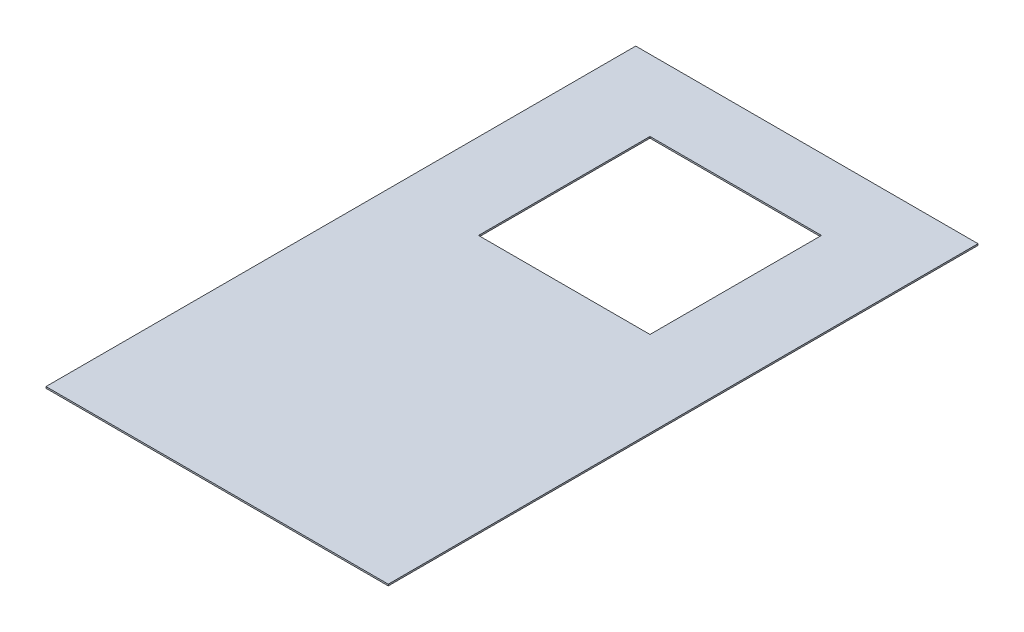
from build123d import *

# Parameters (mm, degrees)
SKETCH1_W               = 1219.2
SKETCH1_H               = 2100.58
BOSS_EXTRUDE1_DEPTH     = 5.55625
SKETCH2_W               = 610.87
SKETCH2_H               = 610.87
CUT_EXTRUDE1_DEPTH      = 1
CUT_EXTRUDE1_DEPTH_BACK = 6.55625


with BuildPart() as part:
    # Sketch1 → Boss-Extrude1 (new body)
    with BuildSketch(Plane(origin=(0, 0, 0), x_dir=(1, 0, 0), z_dir=(0, 1, 0))):
        Rectangle(SKETCH1_W, SKETCH1_H)
    extrude(amount=BOSS_EXTRUDE1_DEPTH)

    # Sketch2 → Cut-Extrude1 (cut, two sides)
    with BuildSketch(Plane(origin=(0, 5.55625, 0), x_dir=(1, 0, 0), z_dir=(0, 1, 0))) as cut_extrude1_sk:
        with Locations((0, 491.49)):
            Rectangle(SKETCH2_W, SKETCH2_H)
    extrude(amount=CUT_EXTRUDE1_DEPTH, mode=Mode.SUBTRACT)
    extrude(cut_extrude1_sk.sketch, amount=-CUT_EXTRUDE1_DEPTH_BACK, mode=Mode.SUBTRACT)


solid = part.part
